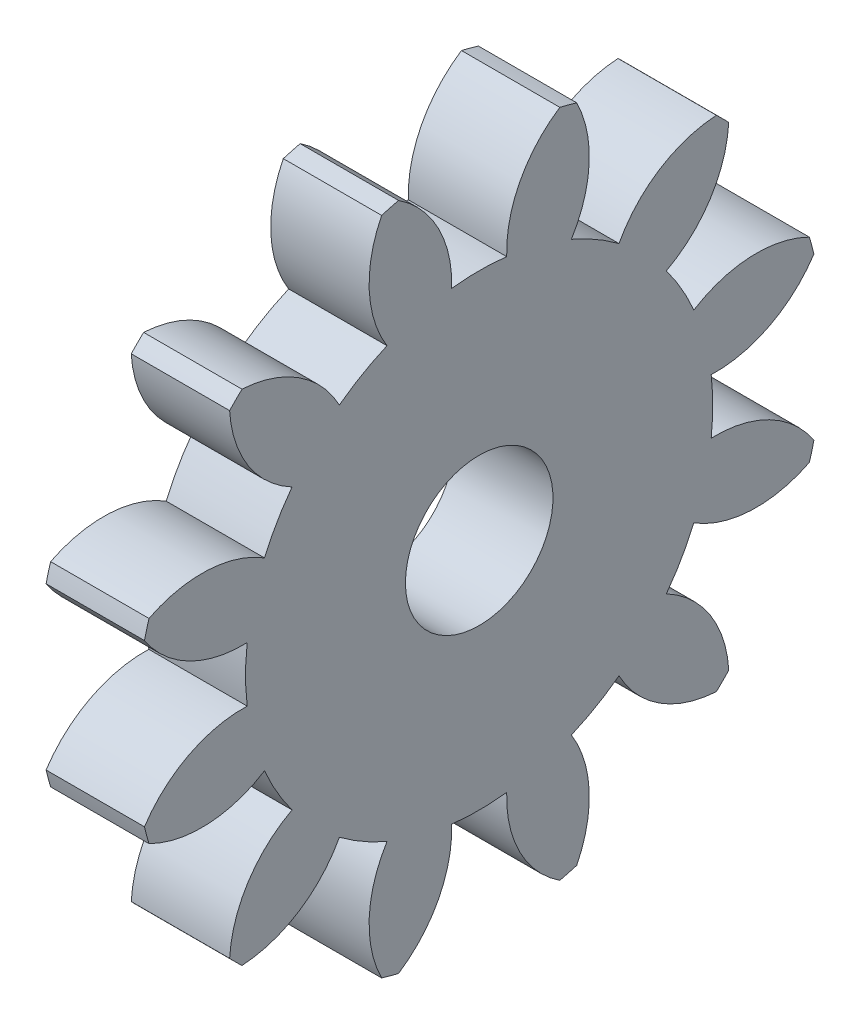
from build123d import *

# Parameters (mm, degrees)
BASPROSKE_W     = 12.7
BASPROSKE_H     = 44.45
TOOTHCUT_DEPTH  = 65.131856358
TEETHCUTS_COUNT = 12
TEETHCUTS_ANGLE = 330
BORSKE_R        = 9.525
BORE_DEPTH      = 25.4000508


with BuildPart() as part:
    # BasProSke → Base-Revolve (revolve)
    with BuildSketch(Plane(origin=(0, 0, 0), x_dir=(1, 0, 0), z_dir=(0, 1, 0)), mode=Mode.PRIVATE) as base_revolve_sk:
        with Locations((6.35, 22.225)):
            Rectangle(BASPROSKE_W, BASPROSKE_H)
    revolve(base_revolve_sk.sketch.rotate(Axis((-10, 0, 0), (1, 0, 0)), 180), axis=Axis((-10, 0, 0), (1, 0, 0)))

    # TooCutSke → ToothCut (cut, through all)
    with BuildSketch(Plane(origin=(0, 0, 0), x_dir=(0, 0, -1), z_dir=(1, 0, 0))):
        with BuildLine():
            ThreePointArc((3.552242783, 29.951316604), (0, 30.16123), (-3.552242783, 29.951316604))
            ThreePointArc((-3.552242783, 29.951316604), (-5.254049238, 37.49538421), (-10.439744342, 43.232776261))
            ThreePointArc((-10.439744342, 43.232776261), (0, 44.4754), (10.439744342, 43.232776261))
            ThreePointArc((10.439744342, 43.232776261), (5.254049238, 37.49538421), (3.552242783, 29.951316604))
        make_face()
    toothcut = extrude(amount=TOOTHCUT_DEPTH, mode=Mode.SUBTRACT)

    # TeethCuts: ToothCut ×12 about axis
    teethcuts_axis = Axis((-10, 0, 0), (1, 0, 0))
    for i in range(1, TEETHCUTS_COUNT):
        add(toothcut.rotate(teethcuts_axis, i * TEETHCUTS_ANGLE / (TEETHCUTS_COUNT - 1)), mode=Mode.SUBTRACT)

    # BorSke → Bore (cut, symmetric)
    with BuildSketch(Plane(origin=(0, 0, 0), x_dir=(0, 0, -1), z_dir=(1, 0, 0))):
        with Locations(Location((0, 0, 0), (0, 0, 180))):
            Circle(BORSKE_R)
    extrude(amount=BORE_DEPTH, both=True, mode=Mode.SUBTRACT)


solid = part.part
